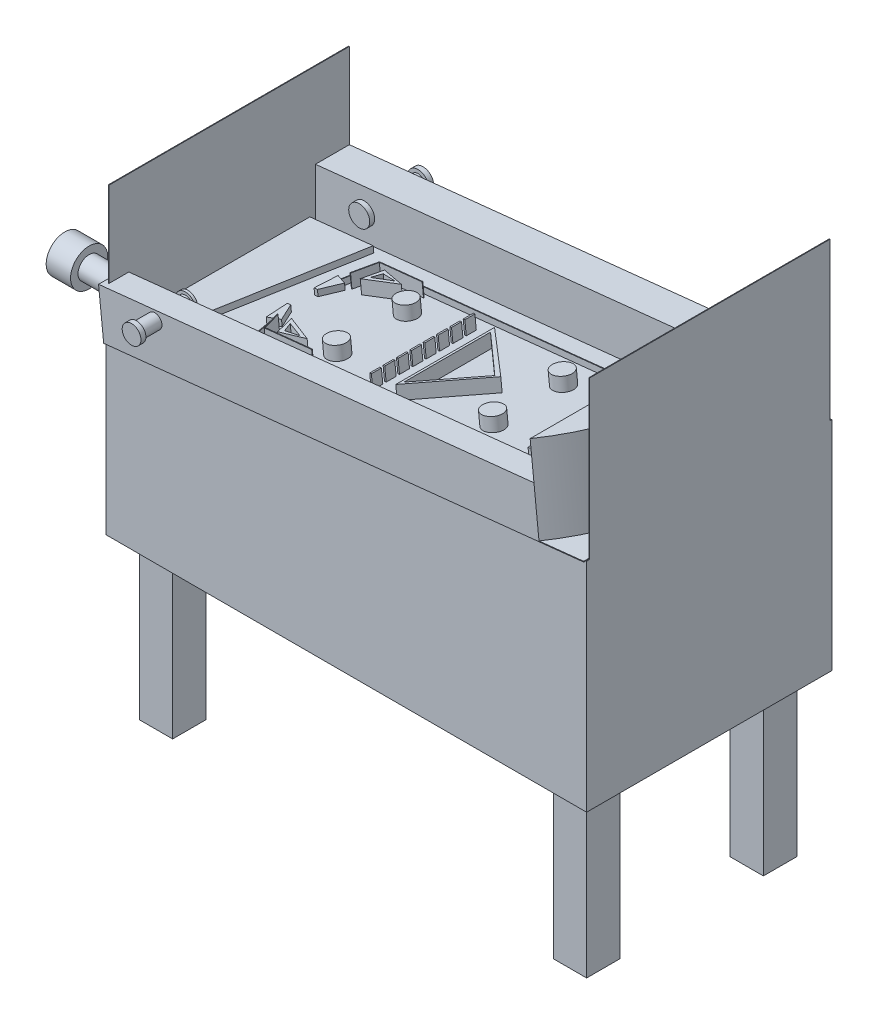
from build123d import *

# Parameters (mm, degrees)
SKETCH1_W                 = 1828.8
SKETCH1_H                 = 914.4
BOSS_EXTRUDE1_DEPTH       = 2.54
SKETCH2_W                 = 2.54
SKETCH2_H                 = 914.4
EXTRUDE_THIN8_DEPTH       = 1143
SKETCH3_W                 = 2.54
SKETCH3_H                 = 914.4
EXTRUDE_THIN9_DEPTH       = 1422.4
SKETCH18_W                = 1836.347462113
SKETCH18_H                = 935.006838284
BOSS_EXTRUDE3_DEPTH       = 2.54
BOSS_EXTRUDE8_DEPTH       = 469.138
BOSS_EXTRUDE8_DEPTH_BACK  = 463.804
SKETCH29_W                = 127
SKETCH29_H                = 127
BOSS_EXTRUDE9_DEPTH       = 609.6
SKETCH30_W                = 170.831498041
SKETCH30_H                = 935.006838284
BOSS_EXTRUDE10_DEPTH      = 322.072
CUT_EXTRUDE1_DEPTH        = 462.268505274
CUT_EXTRUDE1_DEPTH_BACK   = 322.072
SKETCH34_W                = 1665.515964072
SKETCH34_H                = 96.008230777
BOSS_EXTRUDE12_DEPTH      = 183.134
SKETCH36_W                = 1201.173504407
SKETCH36_H                = 54.392379636
BOSS_EXTRUDE14_DEPTH      = 22.86
SKETCH35_W                = 1665.515964072
SKETCH35_H                = 128.980682239
BOSS_EXTRUDE16_DEPTH      = 183.134
BOSS_EXTRUDE18_DEPTH      = 22.86
SKETCH42_R                = 42.406566113
BOSS_EXTRUDE19_DEPTH      = 243.078
BOSS_EXTRUDE19_DEPTH_BACK = 211.074
SKETCH43_R                = 69.134707469
CUT_EXTRUDE3_DEPTH        = 92.71
CUT_EXTRUDE3_DEPTH_BACK   = 5.334
SKETCH45_R                = 70.784383607
BOSS_EXTRUDE20_DEPTH      = 92.71
EXTRUDE_THIN12_DEPTH      = 137.16
EXTRUDE_THIN17_DEPTH      = 137.16
SKETCH58_R                = 27.123852135
BOSS_EXTRUDE21_DEPTH      = 67.818
BOSS_EXTRUDE21_DEPTH_BACK = 137.16
SKETCH59_R                = 39.941527927
BOSS_EXTRUDE22_DEPTH      = 18.796
SKETCH60_R                = 40.58424499
BOSS_EXTRUDE23_DEPTH      = 18.796
SKETCH64_R                = 27.178
BOSS_EXTRUDE25_DEPTH      = 69.596
BOSS_EXTRUDE25_DEPTH_BACK = 116.332
SKETCH66_R                = 35.740500709
BOSS_EXTRUDE27_DEPTH      = 18.796
EXTRUDE_THIN23_DEPTH      = 22.86
BOSS_EXTRUDE30_DEPTH      = 22.86
SKETCH65_R                = 37.645196339
BOSS_EXTRUDE31_DEPTH      = 10.16
SKETCH71_W                = 50.8
SKETCH71_H                = 20.32
BOSS_EXTRUDE33_DEPTH      = 50.8
EXTRUDE_THIN24_DEPTH      = 50.8
BOSS_EXTRUDE34_DEPTH      = 50.8
CUT_EXTRUDE5_DEPTH        = 50.8
CUT_EXTRUDE5_DEPTH_BACK   = 50.8
SKETCH79_R                = 38.1
BOSS_EXTRUDE35_DEPTH      = 50.8
BOSS_EXTRUDE36_DEPTH      = 50.8
CUT_EXTRUDE6_DEPTH        = 50.8
SKETCH82_W                = 6.331058043
SKETCH82_H                = 38.1
BOSS_EXTRUDE37_DEPTH      = 50.8


with BuildPart() as part:
    # Sketch1 → Boss-Extrude1 (new body)
    with BuildSketch(Plane(origin=(0, 0, 0), x_dir=(1, 0, 0), z_dir=(0, 1, 0))):
        Rectangle(SKETCH1_W, SKETCH1_H)
    extrude(amount=BOSS_EXTRUDE1_DEPTH)

    # Sketch3 → Extrude-Thin9 (add)
    with BuildSketch(Plane(origin=(0, 2.54, 0), x_dir=(1, 0, 0), z_dir=(0, 1, 0))):
        with Locations((913.13, 0)):
            Rectangle(SKETCH3_W, SKETCH3_H)
    extrude(amount=EXTRUDE_THIN9_DEPTH)

    # Sketch18 → Boss-Extrude3 (add)
    with BuildSketch(Plane(origin=(-76.384536683, 725.741418896, 0), x_dir=(-0.994506779, -0.104672184, 0), z_dir=(0.104672184, -0.994506779, 0))):
        with Locations((-75.529436557, -10.303419142)):
            Rectangle(SKETCH18_W, SKETCH18_H)
    extrude(amount=BOSS_EXTRUDE3_DEPTH)



with BuildPart() as body_2:
    # Sketch2 → Extrude-Thin8 (new body)
    with BuildSketch(Plane(origin=(0, 2.54, 0), x_dir=(1, 0, 0), z_dir=(0, 1, 0))):
        with Locations((-915.67, 0)):
            Rectangle(SKETCH2_W, SKETCH2_H)
    extrude(amount=EXTRUDE_THIN8_DEPTH)


with BuildPart() as part_1:
    add(part.part)

    add(body_2.part)  # Boss-Extrude8 merges body 2
    # Sketch26 → Boss-Extrude8 (add, two sides)
    with BuildSketch(Plane.XY) as boss_extrude8_sk:
        Polygon((914.4, 0), (-914.4, 0), (-914.4, 637.54), (914.4, 827.2145), align=None)
    extrude(amount=BOSS_EXTRUDE8_DEPTH)
    extrude(boss_extrude8_sk.sketch, amount=-BOSS_EXTRUDE8_DEPTH_BACK)

    # Sketch29 → Boss-Extrude9 (add)
    with BuildSketch(Plane.XZ):
        with Locations((-787.4, 342.138)):
            Rectangle(SKETCH29_W, SKETCH29_H)
        with Locations((-787.4, -330.2)):
            Rectangle(SKETCH29_W, SKETCH29_H)
        with Locations((787.571820229, -330.2)):
            Rectangle(SKETCH29_W, SKETCH29_H)
        with Locations((787.571820229, 342.138)):
            Rectangle(SKETCH29_W, SKETCH29_H)
    extrude(amount=BOSS_EXTRUDE9_DEPTH)

    # Sketch30 → Boss-Extrude10 (add)
    with BuildSketch(Plane(origin=(-76.384536683, 725.741418896, 0), x_dir=(0.994506779, 0.104672184, 0), z_dir=(-0.104672184, 0.994506779, 0))):
        with Locations((908.287418592, -10.303419142)):
            Rectangle(SKETCH30_W, SKETCH30_H)
    extrude(amount=BOSS_EXTRUDE10_DEPTH)

    # Sketch32 → Cut-Extrude1 (cut, two sides)
    with BuildSketch(Plane(origin=(-110.096516426, 1046.04420628, 0), x_dir=(0.994506779, 0.104672184, 0), z_dir=(-0.104672184, 0.994506779, 0))) as cut_extrude1_sk:
        with BuildLine():
            Line((993.703167613, 457.2), (822.871669572, 457.2))
            ThreePointArc((822.871669572, 457.2), (949.657551601, 238.565445741), (993.703167613, -10.303419142))
            Line((993.703167613, -10.303419142), (993.703167613, 457.2))
        make_face()
        with BuildLine():
            Line((993.703167613, -477.806838284), (993.703167613, -10.303419142))
            ThreePointArc((993.703167613, -10.303419142), (949.657551601, -259.172284025), (822.871669572, -477.806838284))
            Line((822.871669572, -477.806838284), (993.703167613, -477.806838284))
        make_face()
    extrude(amount=CUT_EXTRUDE1_DEPTH, mode=Mode.SUBTRACT)
    extrude(cut_extrude1_sk.sketch, amount=-CUT_EXTRUDE1_DEPTH_BACK, mode=Mode.SUBTRACT)

    # Sketch34 → Boss-Extrude12 (add)
    with BuildSketch(Plane(origin=(-76.384536683, 725.741418896, 0), x_dir=(0.994506779, 0.104672184, 0), z_dir=(-0.104672184, 0.994506779, 0))):
        with Locations((-9.886312464, -429.802722896)):
            Rectangle(SKETCH34_W, SKETCH34_H)
    extrude(amount=BOSS_EXTRUDE12_DEPTH)

    # Sketch36 → Boss-Extrude14 (add)
    with BuildSketch(Plane(origin=(-76.384536683, 725.741418896, 0), x_dir=(0.994506779, 0.104672184, 0), z_dir=(-0.104672184, 0.994506779, 0))):
        with Locations((4.305400039, -256.52768963)):
            Rectangle(SKETCH36_W, SKETCH36_H)
    extrude(amount=BOSS_EXTRUDE14_DEPTH)

    # Sketch35 → Boss-Extrude16 (add)
    with BuildSketch(Plane(origin=(-76.384536683, 725.741418896, 0), x_dir=(0.994506779, 0.104672184, 0), z_dir=(-0.104672184, 0.994506779, 0))):
        with Locations((-9.886312464, 392.709658881)):
            Rectangle(SKETCH35_W, SKETCH35_H)
    extrude(amount=BOSS_EXTRUDE16_DEPTH)

    # Sketch38 → Boss-Extrude18 (add)
    with BuildSketch(Plane(origin=(-76.384536683, 725.741418896, 0), x_dir=(0.994506779, 0.104672184, 0), z_dir=(-0.104672184, 0.994506779, 0))):
        Polygon((-838.48920563, -283.723879448), (-717.385278898, -283.723879448), (-596.281352165, 305.143036926), (-838.48920563, 305.143036926), align=None)
    extrude(amount=BOSS_EXTRUDE18_DEPTH)

    # Sketch42 → Boss-Extrude19 (add, two sides)
    with BuildSketch(Plane(origin=(-914.4, 0, 0), x_dir=(0, 0, -1), z_dir=(1, 0, 0))) as boss_extrude19_sk:
        with Locations((-327.028367047, 706.390828861)):
            Circle(SKETCH42_R)
    extrude(amount=BOSS_EXTRUDE19_DEPTH)
    extrude(boss_extrude19_sk.sketch, amount=-BOSS_EXTRUDE19_DEPTH_BACK)

    # Sketch43 → Cut-Extrude3 (cut, two sides)
    with BuildSketch(Plane.ZY.offset(1125.474)) as cut_extrude3_sk:
        with Locations((327.028367047, 706.390828861)):
            Circle(SKETCH43_R)
    extrude(amount=CUT_EXTRUDE3_DEPTH, mode=Mode.SUBTRACT)
    extrude(cut_extrude3_sk.sketch, amount=-CUT_EXTRUDE3_DEPTH_BACK, mode=Mode.SUBTRACT)

    # Sketch45 → Boss-Extrude20 (add)
    with BuildSketch(Plane.ZY.offset(1120.14)):
        with Locations((327.028367047, 706.390828861)):
            Circle(SKETCH45_R)
    extrude(amount=BOSS_EXTRUDE20_DEPTH)

    # Sketch53 → Extrude-Thin12 (add)
    with BuildSketch(Plane(origin=(-76.384536683, 725.741418896, 0), x_dir=(0.994506779, 0.104672184, 0), z_dir=(-0.104672184, 0.994506779, 0))):
        with BuildLine():
            ThreePointArc((615.084985105, -359.687605054), (821.614775239, -15.734143646), (615.084985105, 328.219317761))
            Line((615.084985105, 328.219317761), (616.278768009, 330.461299558))
            ThreePointArc((616.278768009, 330.461299558), (824.154775239, -15.734143646), (616.278768009, -361.929586851))
            Line((616.278768009, -361.929586851), (615.084985105, -359.687605054))
        make_face()
    extrude(amount=EXTRUDE_THIN12_DEPTH)

    # Sketch57 → Extrude-Thin17 (add)
    with BuildSketch(Plane(origin=(-76.384536683, 725.741418896, 0), x_dir=(0.994506779, 0.104672184, 0), z_dir=(-0.104672184, 0.994506779, 0))):
        with BuildLine():
            ThreePointArc((614.455503555, -363.130851714), (593.906446274, -377.41275714), (568.948443266, -379.238863267))
            Line((568.948443266, -379.238863267), (569.438444072, -376.74657532))
            ThreePointArc((569.438444072, -376.74657532), (593.058898696, -375.018333806), (612.506691651, -361.501823733))
            Line((612.506691651, -361.501823733), (614.455503555, -363.130851714))
        make_face()
    extrude(amount=EXTRUDE_THIN17_DEPTH)

    # Sketch58 → Boss-Extrude21 (add, two sides)
    with BuildSketch(Plane(origin=(0, 0, -457.2), x_dir=(-1, 0, 0), z_dir=(0, 0, -1))) as boss_extrude21_sk:
        with Locations((720.973211357, 762.171149243)):
            Circle(SKETCH58_R)
    extrude(amount=BOSS_EXTRUDE21_DEPTH)
    extrude(boss_extrude21_sk.sketch, amount=-BOSS_EXTRUDE21_DEPTH_BACK)

    # Sketch59 → Boss-Extrude22 (add)
    with BuildSketch(Plane.XY.offset(-320.04)):
        with Locations((-720.973211357, 762.171149243)):
            Circle(SKETCH59_R)
    extrude(amount=BOSS_EXTRUDE22_DEPTH)

    # Sketch60 → Boss-Extrude23 (add)
    with BuildSketch(Plane(origin=(0, 0, -525.018), x_dir=(-1, 0, 0), z_dir=(0, 0, -1))):
        with Locations((720.973211357, 762.171149243)):
            Circle(SKETCH60_R)
    extrude(amount=BOSS_EXTRUDE23_DEPTH)

    # Sketch64 → Boss-Extrude25 (add, two sides)
    with BuildSketch(Plane.XY.offset(477.806838284)) as boss_extrude25_sk:
        with Locations((-719.570145616, 805.713061184)):
            Circle(SKETCH64_R)
    extrude(amount=BOSS_EXTRUDE25_DEPTH)
    extrude(boss_extrude25_sk.sketch, amount=-BOSS_EXTRUDE25_DEPTH_BACK)

    # Sketch66 → Boss-Extrude27 (add)
    with BuildSketch(Plane.XY.offset(547.402838284)):
        with Locations((-719.570145616, 805.713061184)):
            Circle(SKETCH66_R)
    extrude(amount=BOSS_EXTRUDE27_DEPTH)

    # Sketch68 → Extrude-Thin23 (add)
    with BuildSketch(Plane(origin=(-76.384536683, 725.741418896, 0), x_dir=(0.994506779, 0.104672184, 0), z_dir=(-0.104672184, 0.994506779, 0))):
        Polygon((-541.369416043, 121.558775208), (-519.153675256, 238.853469296), (-240.81237418, 238.853469296), (616.903145012, 238.853469296), (616.903145012, 241.393469296), (-240.81237418, 241.393469296), (-521.257753538, 241.393469296), (-543.865047832, 122.031450544), align=None)
        Polygon((-541.369416043, -121.558775208), (-519.153675256, -238.853469296), (-240.81237418, -238.853469296), (616.903145012, -238.853469296), (616.903145012, -236.313469296), (-240.81237418, -236.313469296), (-517.049596974, -236.313469296), (-538.873784254, -121.086099872), align=None)
    extrude(amount=EXTRUDE_THIN23_DEPTH)

    # Sketch70 → Boss-Extrude30 (add)
    with BuildSketch(Plane(origin=(-76.384536683, 725.741418896, 0), x_dir=(0.994506779, 0.104672184, 0), z_dir=(-0.104672184, 0.994506779, 0))):
        Polygon((-561.143244721, 136.604656678), (-519.526167315, 119.842041478), (-553.704628667, 50.8), (-566.709893432, 50.8), align=None)
        Polygon((-566.709893432, -50.8), (-553.704628667, -50.8), (-519.526167315, -119.842041478), (-561.143244721, -136.604656678), align=None)
    extrude(amount=BOSS_EXTRUDE30_DEPTH)

    # Sketch65 → Boss-Extrude31 (add)
    with BuildSketch(Plane(origin=(0, 0, 361.474838284), x_dir=(-1, 0, 0), z_dir=(0, 0, -1))):
        with Locations((719.570145616, 805.713061184)):
            Circle(SKETCH65_R)
    extrude(amount=BOSS_EXTRUDE31_DEPTH)

    # Sketch71 → Boss-Extrude33 (add)
    with BuildSketch(Plane(origin=(-76.384536683, 725.741418896, 0), x_dir=(0.994506779, 0.104672184, 0), z_dir=(-0.104672184, 0.994506779, 0))):
        with Locations((540.636183413, 137.253469296)):
            Rectangle(SKETCH71_W, SKETCH71_H)
        with Locations((540.636183413, 25.493469296)):
            Rectangle(SKETCH71_W, SKETCH71_H)
        with Locations((540.636183413, -86.266530704)):
            Rectangle(SKETCH71_W, SKETCH71_H)
        with Locations((540.636183413, -198.026530704)):
            Rectangle(SKETCH71_W, SKETCH71_H)
    extrude(amount=BOSS_EXTRUDE33_DEPTH)

    # Sketch74 → Extrude-Thin24 (add)
    with BuildSketch(Plane(origin=(-76.384536683, 725.741418896, 0), x_dir=(0.994506779, 0.104672184, 0), z_dir=(-0.104672184, 0.994506779, 0))):
        Polygon((-511.586981677, 135.876859853), (-488.993504749, 225.474191126), (-323.453767095, 225.474191126), (-323.453767095, 222.934191126), (-487.014496169, 222.934191126), (-509.124080549, 135.255797831), align=None)
        Polygon((-511.586981677, -138.136408), (-488.993504749, -208.818868272), (-309.289939274, -208.818868272), (-309.289939274, -211.358868272), (-490.848206269, -211.358868272), (-514.006386394, -138.909764847), align=None)
    extrude(amount=EXTRUDE_THIN24_DEPTH)

    # Sketch76 → Boss-Extrude34 (add)
    with BuildSketch(Plane(origin=(-76.384536683, 725.741418896, 0), x_dir=(0.994506779, 0.104672184, 0), z_dir=(-0.104672184, 0.994506779, 0))):
        Polygon((-467.45141899, 130.685186555), (-359.064900964, 179.173891988), (-447.639065594, 203.330482342), align=None)
        Polygon((-359.064900964, -179.173891988), (-447.639065594, -203.330482342), (-467.45141899, -130.685186555), align=None)
    extrude(amount=BOSS_EXTRUDE34_DEPTH)

    # Sketch78 → Cut-Extrude5 (cut, two sides)
    with BuildSketch(Plane(origin=(-76.384536683, 725.741418896, 0), x_dir=(0.994506779, 0.104672184, 0), z_dir=(-0.104672184, 0.994506779, 0))) as cut_extrude5_sk:
        Polygon((-436.685224518, 187.62749247), (-450.889562933, 152.116646433), (-384.316930879, 180.647774456), align=None)
        Polygon((-450.889562933, -152.116646433), (-384.316930879, -180.647774456), (-436.685224518, -187.62749247), align=None)
    extrude(amount=CUT_EXTRUDE5_DEPTH, mode=Mode.SUBTRACT)
    extrude(cut_extrude5_sk.sketch, amount=-CUT_EXTRUDE5_DEPTH_BACK, mode=Mode.SUBTRACT)

    # Sketch79 → Boss-Extrude35 (add)
    with BuildSketch(Plane(origin=(-76.384536683, 725.741418896, 0), x_dir=(0.994506779, 0.104672184, 0), z_dir=(-0.104672184, 0.994506779, 0))):
        with Locations((-298.672676105, 137.253469296)):
            Circle(SKETCH79_R)
        with Locations((-298.672676105, -127.731499812)):
            Circle(SKETCH79_R)
        with Locations((298.672676105, 137.253469296)):
            Circle(SKETCH79_R)
        with Locations((298.672676105, -127.731499812)):
            Circle(SKETCH79_R)
    extrude(amount=BOSS_EXTRUDE35_DEPTH)

    # Sketch80 → Boss-Extrude36 (add)
    with BuildSketch(Plane(origin=(-76.384536683, 725.741418896, 0), x_dir=(0.994506779, 0.104672184, 0), z_dir=(-0.104672184, 0.994506779, 0))):
        Polygon((195.700652086, 5.88703021), (0, 176.851813717), (0, -199.065499212), align=None)
    extrude(amount=BOSS_EXTRUDE36_DEPTH)

    # Sketch81 → Cut-Extrude6 (cut)
    with BuildSketch(Plane(origin=(-81.701883646, 776.262363279, 0), x_dir=(0.994506779, 0.104672184, 0), z_dir=(-0.104672184, 0.994506779, 0))):
        Polygon((8.956286154, 152.521585359), (8.956286154, -176.651013418), (178.82114035, 0), align=None)
    extrude(amount=-CUT_EXTRUDE6_DEPTH, mode=Mode.SUBTRACT)

    # Sketch82 → Boss-Extrude37 (add)
    with BuildSketch(Plane(origin=(-76.384536683, 725.741418896, 0), x_dir=(0.994506779, 0.104672184, 0), z_dir=(-0.104672184, 0.994506779, 0))):
        with Locations((-94.948786188, 123.420051639)):
            Rectangle(SKETCH82_W, SKETCH82_H)
        with Locations((-94.948786188, 174.220051639)):
            Rectangle(SKETCH82_W, SKETCH82_H)
        with Locations((-94.948786188, 72.620051639)):
            Rectangle(SKETCH82_W, SKETCH82_H)
        with Locations((-94.948786188, 21.820051639)):
            Rectangle(SKETCH82_W, SKETCH82_H)
        with Locations((-94.948786188, -28.979948361)):
            Rectangle(SKETCH82_W, SKETCH82_H)
        with Locations((-94.948786188, -79.779948361)):
            Rectangle(SKETCH82_W, SKETCH82_H)
        with Locations((-94.948786188, -130.579948361)):
            Rectangle(SKETCH82_W, SKETCH82_H)
        with Locations((-94.948786188, -181.379948361)):
            Rectangle(SKETCH82_W, SKETCH82_H)
    extrude(amount=BOSS_EXTRUDE37_DEPTH)


solid = part_1.part
